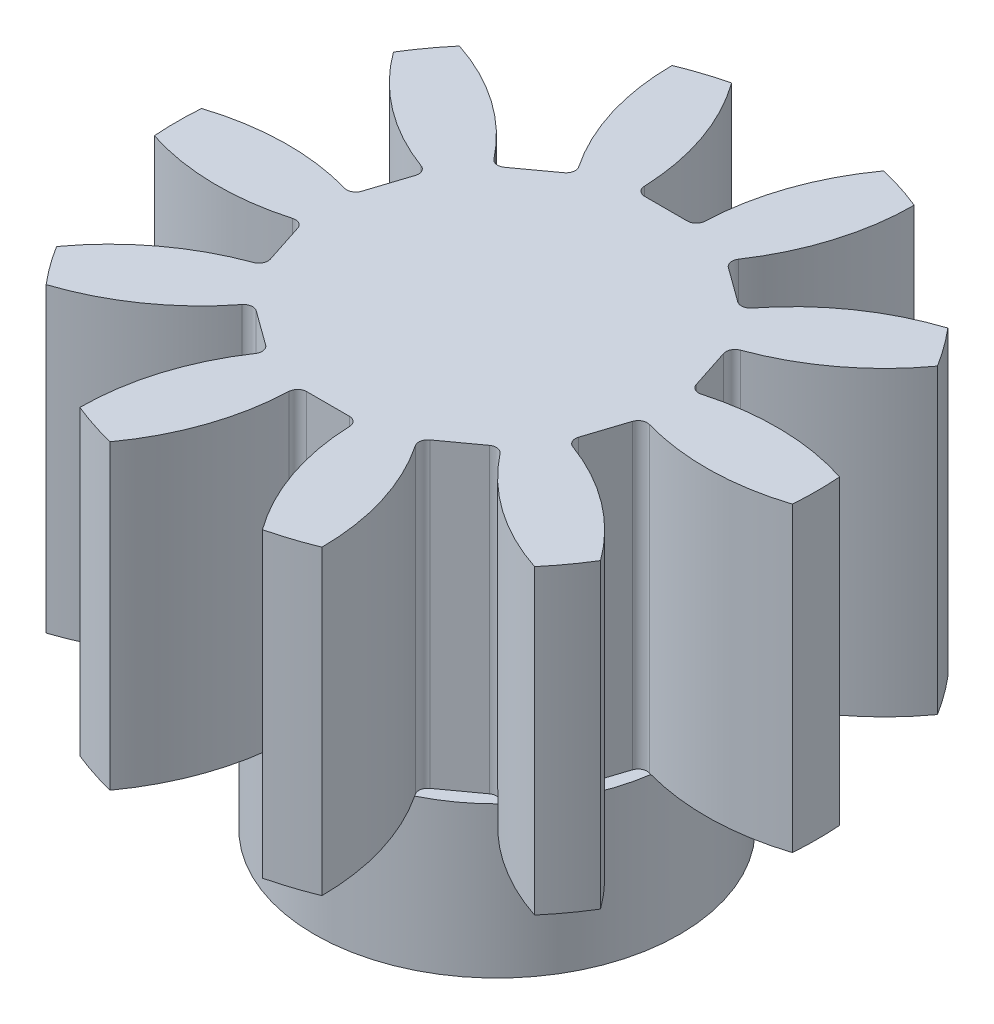
from build123d import *

# Parameters (mm, degrees)
SKETCH1_R           = 6.05
BOSS_EXTRUDE1_DEPTH = 5
SKETCH2_R           = 10.6
BOSS_EXTRUDE2_DEPTH = 10
CUT_EXTRUDE1_DEPTH  = 10
CIRPATTERN1_COUNT   = 10


with BuildPart() as part:
    # Sketch1 → Boss-Extrude1 (new body)
    with BuildSketch(Plane(origin=(0, 0, 0), x_dir=(1, 0, 0), z_dir=(0, 1, 0))):
        Circle(SKETCH1_R)
        with BuildLine():
            Line((-1.6, 2.596632435), (1.6, 2.596632435))
            ThreePointArc((1.6, 2.596632435), (0, -3.05), (-1.6, 2.596632435))
        make_face(mode=Mode.SUBTRACT)
    extrude(amount=BOSS_EXTRUDE1_DEPTH)

    # Sketch2 → Boss-Extrude2 (add)
    with BuildSketch(Plane(origin=(0, 5, 0), x_dir=(1, 0, 0), z_dir=(0, 1, 0))):
        Circle(SKETCH2_R)
    extrude(amount=BOSS_EXTRUDE2_DEPTH)

    # Sketch3 → Cut-Extrude1 (cut)
    with BuildSketch(Plane(origin=(0, 15, 0), x_dir=(1, 0, 0), z_dir=(0, 1, 0))):
        with BuildLine():
            Line((0.705423459, 5.6), (-0.705423459, 5.6))
            ThreePointArc((-0.705423459, 5.6), (-0.913686499, 5.684068284), (-1.00522743, 5.889156627))
            ThreePointArc((-1.00522743, 5.889156627), (-3.446318924, 11.358179096), (-9, 13.6))
            Line((-9, 13.6), (9, 13.6))
            ThreePointArc((9, 13.6), (3.446318924, 11.358179096), (1.00522743, 5.889156627))
            ThreePointArc((1.00522743, 5.889156627), (0.913686499, 5.684068284), (0.705423459, 5.6))
        make_face()
    cut_extrude1 = extrude(amount=-CUT_EXTRUDE1_DEPTH, mode=Mode.SUBTRACT)

    # CirPattern1: Cut-Extrude1 ×10 about axis
    cirpattern1_axis = Axis((0, 0, 0), (0, 1, 0))
    for i in range(1, CIRPATTERN1_COUNT):
        add(cut_extrude1.rotate(cirpattern1_axis, i * 360 / CIRPATTERN1_COUNT), mode=Mode.SUBTRACT)


solid = part.part
